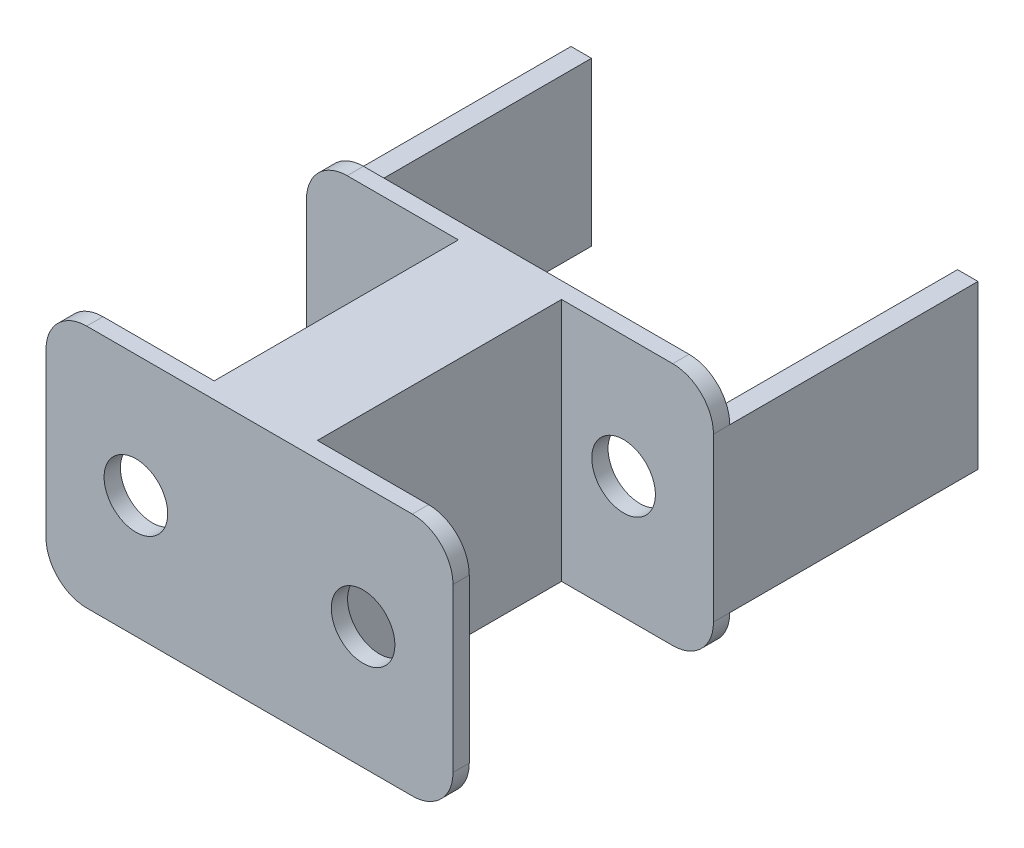
from build123d import *

# Parameters (mm, degrees)
EXTRUDE_1_DEPTH     = 68
SKETCH_2_W          = 49.215089209
SKETCH_2_H          = 60
CUT_EXTRUDE_1_DEPTH = 60
SKETCH_3_R          = 7.815290935
CUT_EXTRUDE_2_DEPTH = 68
SKETCH_3_4_R        = 7.815290935
CUT_EXTRUDE_3_DEPTH = 68
SKETCH_5_W          = 5.029333187
SKETCH_5_H          = 40
EXTRUDE_2_DEPTH     = 61


with BuildPart() as part:
    # Эскиз1 → Бобышка-Вытянуть1 (new body)
    with BuildSketch(Plane.XY):
        with BuildLine():
            Line((-90, 60), (-10, 60))
            ThreePointArc((-10, 60), (-2.928932188, 57.071067812), (0, 50))
            Line((0, 50), (0, 10))
            ThreePointArc((0, 10), (-2.928932188, 2.928932188), (-10, 0))
            Line((-10, 0), (-90, 0))
            ThreePointArc((-90, 0), (-97.071067812, 2.928932188), (-100, 10))
            Line((-100, 10), (-100, 50))
            ThreePointArc((-100, 50), (-97.071067812, 57.071067812), (-90, 60))
        make_face()
    extrude(amount=EXTRUDE_1_DEPTH)

    # Эскиз2 → Вырез-Вытянуть1 (cut)
    with BuildSketch(Plane(origin=(0, 60, 0), x_dir=(1, 0, 0), z_dir=(0, 1, 0))):
        with Locations((-12.715841509, -34)):
            Rectangle(SKETCH_2_W, SKETCH_2_H)
        with Locations((-87.284158491, -34)):
            Rectangle(SKETCH_2_W, SKETCH_2_H)
    extrude(amount=-CUT_EXTRUDE_1_DEPTH, mode=Mode.SUBTRACT)

    # Эскиз3 → Вырез-Вытянуть2 (cut)
    with BuildSketch(Plane(origin=(0, 0, 0), x_dir=(-1, 0, 0), z_dir=(0, 0, -1))):
        with Locations((22.08824666, 30)):
            Circle(SKETCH_3_R)
    extrude(amount=-CUT_EXTRUDE_2_DEPTH, mode=Mode.SUBTRACT)

    # Эскиз3<4> → Вырез-Вытянуть3 (cut)
    with BuildSketch(Plane(origin=(0, 0, 0), x_dir=(-1, 0, 0), z_dir=(0, 0, -1))):
        with Locations((77.91175334, 30)):
            Circle(SKETCH_3_4_R)
        with Locations((22.08824666, 30)):
            Circle(SKETCH_3_4_R)
    extrude(amount=-CUT_EXTRUDE_3_DEPTH, mode=Mode.SUBTRACT)

    # Эскиз5 → Бобышка-Вытянуть2 (add)
    with BuildSketch(Plane(origin=(0, 0, 0), x_dir=(-1, 0, 0), z_dir=(0, 0, -1))):
        with Locations((2.514666594, 30)):
            Rectangle(SKETCH_5_W, SKETCH_5_H)
        with Locations((97.485333407, 30)):
            Rectangle(SKETCH_5_W, SKETCH_5_H)
    extrude(amount=EXTRUDE_2_DEPTH)


solid = part.part
